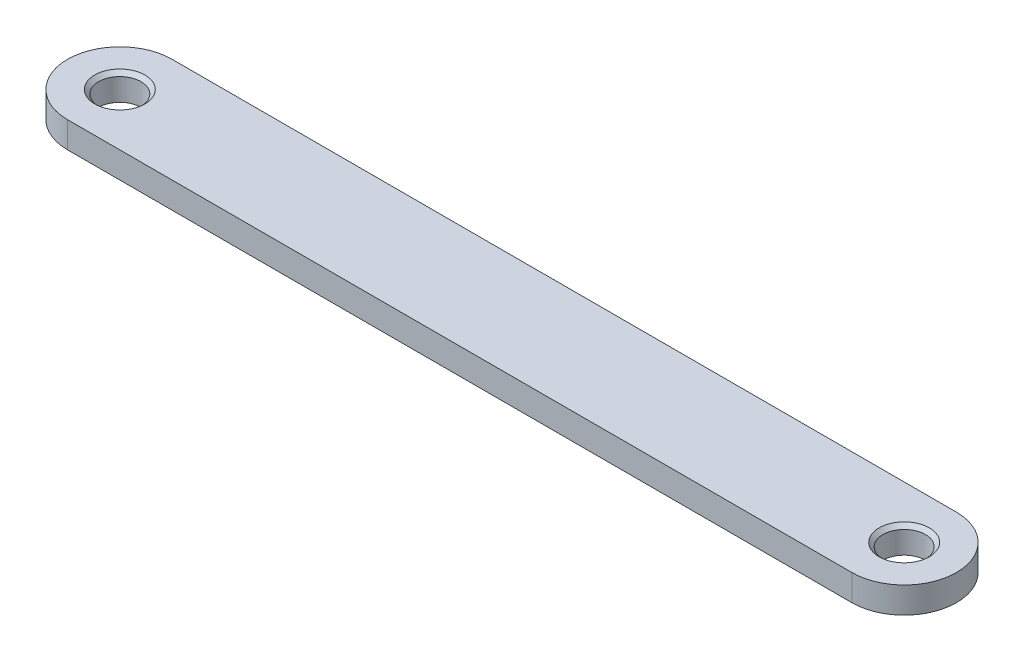
from build123d import *

# Parameters (mm, degrees)
SKETCH1_R                        = 2.5796875
BOSS_EXTRUDE1_DEPTH              = 3.175
F_10_32_TAPPED_HOLE3_D           = 4.0386
F_10_32_TAPPED_HOLE3_CSINK_D     = 6.096
F_10_32_TAPPED_HOLE3_CSINK_ANGLE = 90


with BuildPart() as part:
    # Sketch1 → Boss-Extrude1 (new body)
    with BuildSketch(Plane(origin=(0, 0, 0), x_dir=(1, 0, 0), z_dir=(0, 1, 0))):
        with BuildLine():
            Line((-47.625, 6.35), (47.625, 6.35))
            ThreePointArc((47.625, 6.35), (53.975, 0), (47.625, -6.35))
            Line((47.625, -6.35), (-47.625, -6.35))
            ThreePointArc((-47.625, -6.35), (-53.975, 0), (-47.625, 6.35))
        make_face()
        with Locations((47.625, 0)):
            Circle(SKETCH1_R, mode=Mode.SUBTRACT)
        with Locations((-47.625, 0)):
            Circle(SKETCH1_R, mode=Mode.SUBTRACT)
    extrude(amount=BOSS_EXTRUDE1_DEPTH)

    # #10-32 Tapped Hole3 (through all)
    with Locations(Plane(origin=(0, 3.175, 0), x_dir=(1, 0, 0), z_dir=(0, 1, 0))):
        with Locations((-47.625, 0), (47.625, 0)):
            CounterSinkHole(F_10_32_TAPPED_HOLE3_D / 2, F_10_32_TAPPED_HOLE3_CSINK_D / 2, counter_sink_angle=F_10_32_TAPPED_HOLE3_CSINK_ANGLE)


solid = part.part
